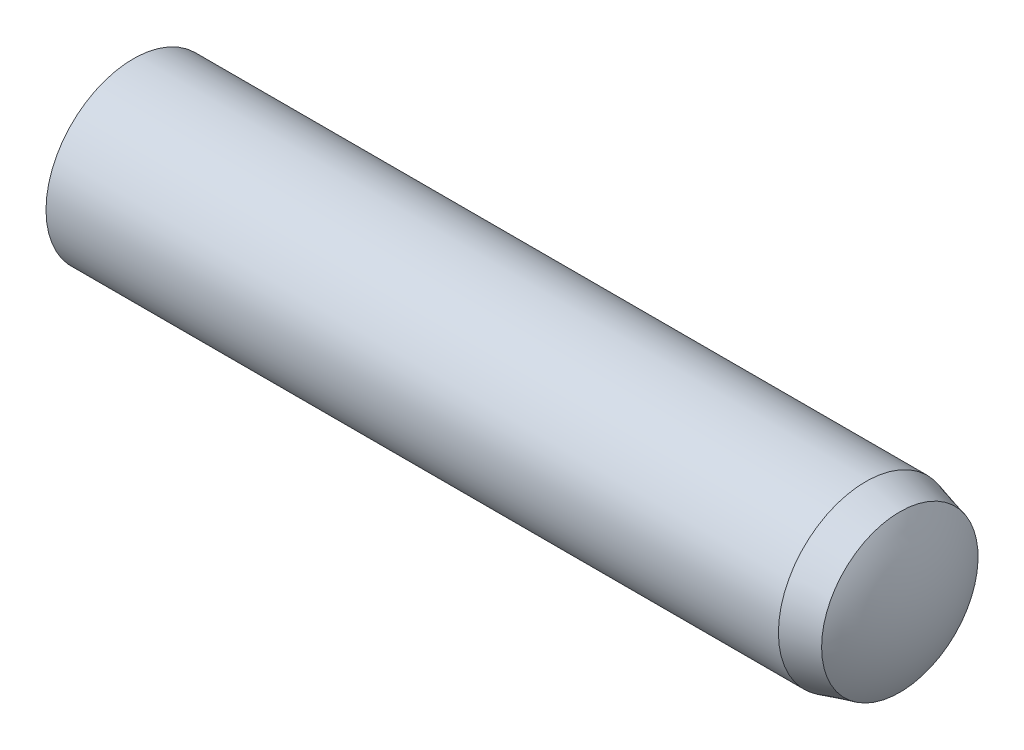
from build123d import *

# Parameters (mm, degrees)
SKETCH2_R           = 1.5
EXTRUDE1_DEPTH      = 7
EXTRUDE1_DEPTH_BACK = 7


with BuildPart() as part:
    # Sketch2 → Extrude1 (new body, two sides)
    with BuildSketch(Plane(origin=(0, 0, 0), x_dir=(0, 0, -1), z_dir=(1, 0, 0))) as extrude1_sk:
        Circle(SKETCH2_R)
    extrude(amount=EXTRUDE1_DEPTH)
    extrude(extrude1_sk.sketch, amount=-EXTRUDE1_DEPTH_BACK)

    # Sketch5 → Cut-Revolve1 (revolve, cut)
    with BuildSketch(Plane.XY):
        with BuildLine():
            Line((6.025, 1.5), (6.025, 2))
            Line((6.025, 2), (7.5, 2))
            Line((7.5, 2), (7.5, 0))
            Line((7.5, 0), (7, 0))
            ThreePointArc((7, 0), (6.90052754, 0.699360389), (6.61, 1.343249722))
            Line((6.61, 1.343249722), (6.025, 1.5))
        make_face()
        with BuildLine():
            Line((-6.55, 1.5), (-6.55, 2))
            Line((-6.55, 2), (-7.5, 2))
            Line((-7.5, 2), (-7.5, 0))
            Line((-7.5, 0), (-7, 0))
            ThreePointArc((-7, 0), (-6.885076627, 0.783022988), (-6.55, 1.5))
        make_face()
    revolve(axis=Axis((-7, 0, 0), (1, 0, 0)), mode=Mode.SUBTRACT)


solid = part.part
